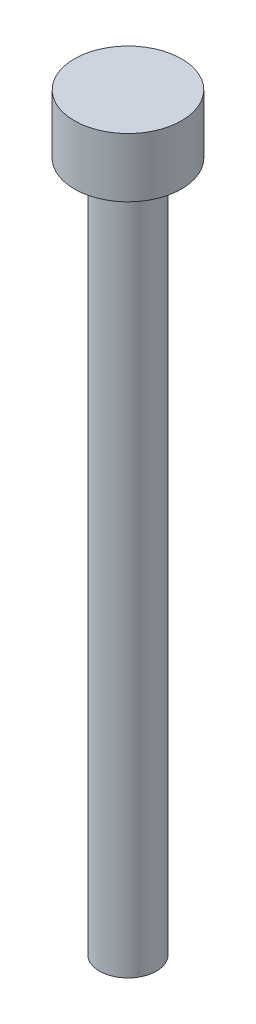
from build123d import *

# Parameters (mm, degrees)
SKETCH1_R           = 2.72
BOSS_EXTRUDE1_DEPTH = 3
SKETCH2_R           = 1.44
BOSS_EXTRUDE2_DEPTH = 35


with BuildPart() as part:
    # Sketch1 → Boss-Extrude1 (new body)
    with BuildSketch(Plane(origin=(0, 0, 0), x_dir=(1, 0, 0), z_dir=(0, 1, 0))):
        Circle(SKETCH1_R)
    extrude(amount=BOSS_EXTRUDE1_DEPTH)

    # Sketch2 → Boss-Extrude2 (add)
    with BuildSketch(Plane.XZ):
        Circle(SKETCH2_R)
    extrude(amount=BOSS_EXTRUDE2_DEPTH)


solid = part.part
